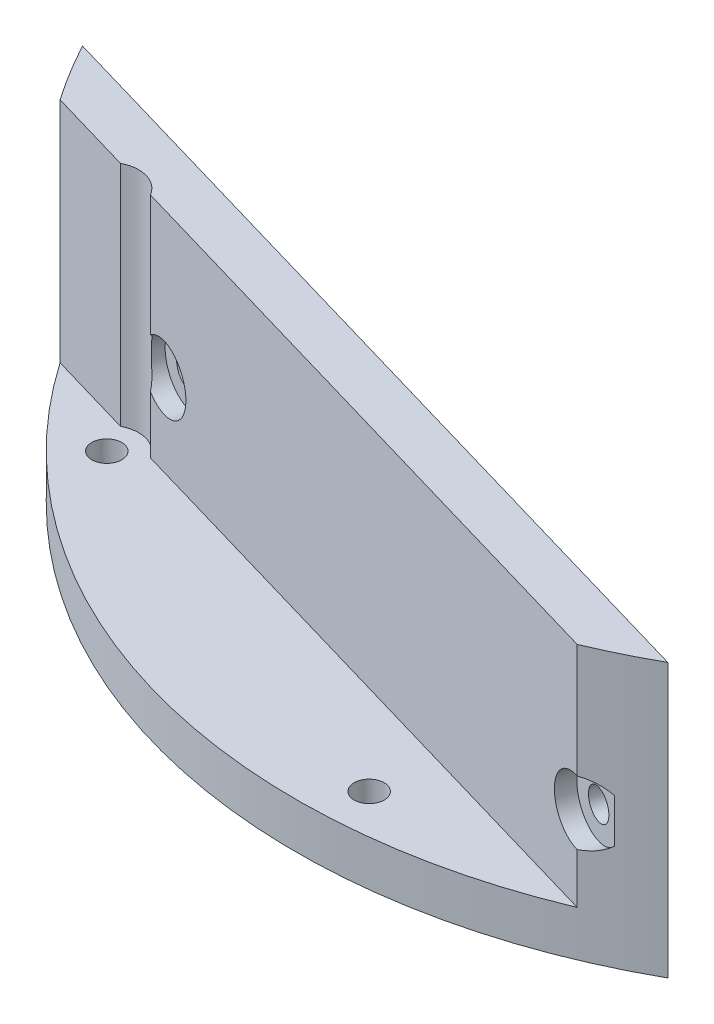
from build123d import *

# Parameters (mm, degrees)
SKETCH1_R           = 1.65
BOSS_EXTRUDE1_DEPTH = 5
BOSS_EXTRUDE2_DEPTH = 25
SKETCH3_R           = 1.65
CUT_EXTRUDE1_DEPTH  = 31.640005718
SKETCH4_R           = 3.5
CUT_EXTRUDE2_DEPTH  = 2
SKETCH5_R           = 67.5
SKETCH5_R_2         = 66.25
CUT_EXTRUDE3_DEPTH  = 31.0000001


with BuildPart() as part:
    # Sketch1 → Boss-Extrude1 (new body)
    with BuildSketch(Plane(origin=(0, 0, 0), x_dir=(1, 0, 0), z_dir=(0, 1, 0))):
        with BuildLine():
            ThreePointArc((-58.769725256, -31.225340563), (-18.644922026, -63.884813396), (32.748082014, -57.935012077))
            Line((32.748082014, -57.935012077), (-58.769725256, -31.225340563))
        make_face()
        with Locations((-43.522422382, -43.522422382)):
            Circle(SKETCH1_R, mode=Mode.SUBTRACT)
        with Locations((3.221278107, -61.465647864)):
            Circle(SKETCH1_R, mode=Mode.SUBTRACT)
    extrude(amount=BOSS_EXTRUDE1_DEPTH)

    # Sketch2 → Boss-Extrude2 (add)
    with BuildSketch(Plane(origin=(0, 5, 0), x_dir=(1, 0, 0), z_dir=(0, 1, 0))):
        with BuildLine():
            Line((-58.769725256, -31.225340563), (32.748082014, -57.935012077))
            ThreePointArc((32.748082014, -57.935012077), (29.480015366, -59.664320946), (26.120952253, -61.20946294))
            Line((26.120952253, -61.20946294), (-40.494047404, -41.767730103))
            ThreePointArc((-40.494047404, -41.767730103), (-42.54184797, -40.162589972), (-45.131562946, -40.414261085))
            Line((-45.131562946, -40.414261085), (-54.944236671, -37.550410872))
            ThreePointArc((-54.944236671, -37.550410872), (-56.94486731, -34.441030575), (-58.769725256, -31.225340563))
        make_face()
    extrude(amount=BOSS_EXTRUDE2_DEPTH)

    # Sketch3 → Cut-Extrude1 (cut, through all)
    with BuildSketch(Plane(origin=(-14.411642209, 0, 49.379936906), x_dir=(0.959952117, 0, 0.280164118), z_dir=(-0.280164118, 0, 0.959952117))):
        with Locations((41.56355859, 14)):
            Circle(SKETCH3_R)
        with Locations((-24.93644141, 14)):
            Circle(SKETCH3_R)
    extrude(amount=-CUT_EXTRUDE1_DEPTH, mode=Mode.SUBTRACT)

    # Sketch4 → Cut-Extrude2 (cut)
    with BuildSketch(Plane(origin=(-14.411642209, 0, 49.379936906), x_dir=(0.959952117, 0, 0.280164118), z_dir=(-0.280164118, 0, 0.959952117))):
        with Locations((41.56355859, 14)):
            Circle(SKETCH4_R)
        with Locations((-24.93644141, 14)):
            Circle(SKETCH4_R)
    extrude(amount=-CUT_EXTRUDE2_DEPTH, mode=Mode.SUBTRACT)

    # Sketch5 → Cut-Extrude3 (cut, through all)
    with BuildSketch(Plane.XZ):
        Circle(SKETCH5_R)
        Circle(SKETCH5_R_2, mode=Mode.SUBTRACT)
    extrude(amount=-CUT_EXTRUDE3_DEPTH, mode=Mode.SUBTRACT)


solid = part.part
